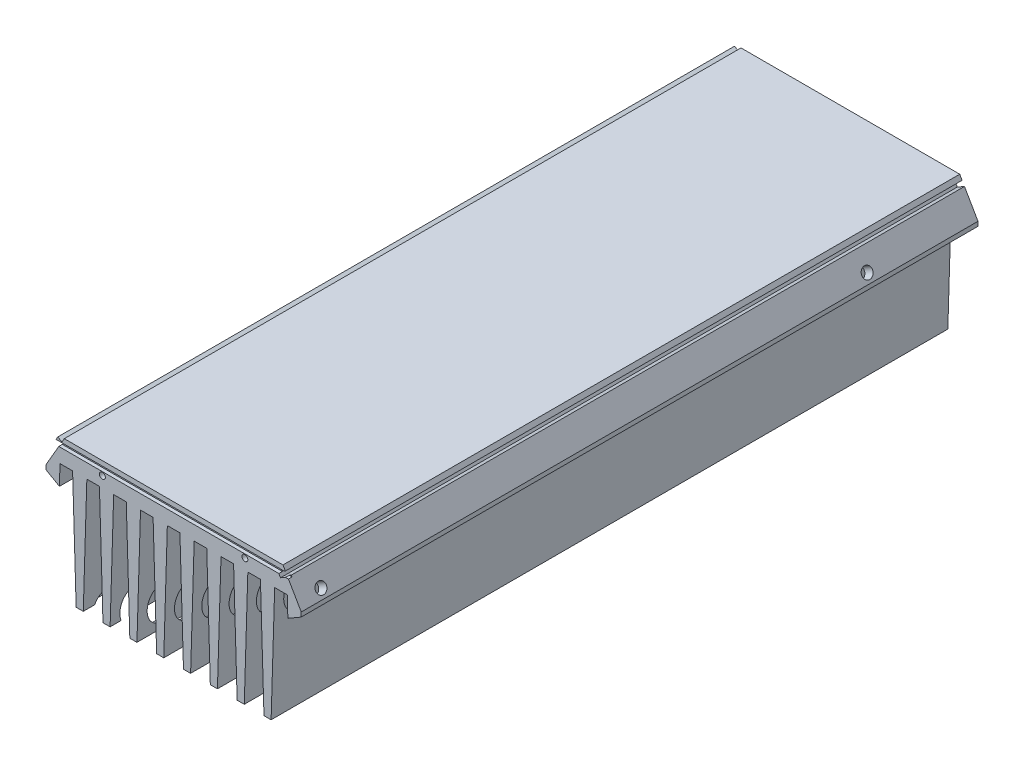
from build123d import *

# Parameters (mm, degrees)
RESSALTO_EXTRUS_O1_DEPTH   = 285
CORTE_EXTRUS_O1_DEPTH      = 1
CORTE_EXTRUS_O1_DEPTH_BACK = 286
ESBO_O3_R                  = 1.25
CORTE_EXTRUS_O2_DEPTH      = 10
ESBO_O4_W                  = 1.5
ESBO_O4_H                  = 2
CORTE_EXTRUS_O3_DEPTH      = 122.633155154
CORTE_EXTRUS_O3_DEPTH_BACK = 1
ESBO_O5_R                  = 1.65
CORTE_EXTRUS_O4_DEPTH      = 10
ESBO_O6_R                  = 2.25
CORTE_EXTRUS_O5_DEPTH      = 7.663465826
CORTE_EXTRUS_O5_DEPTH_BACK = 116.931069713
CORTE_EXTRUS_O6_START      = -4
ESBO_O8_R                  = 6
CORTE_EXTRUS_O6_DEPTH      = 100


with BuildPart() as part:
    # Esboço1 → Ressalto-extrusão1 (new body)
    with BuildSketch(Plane.XY):
        Polygon((0, 59), (155, 59), (155, 49), (153.95, 49), (152.45, 0), (149.45, 0), (147.95, 49), (142.65, 49), (141.15, 0), (138.15, 0), (136.65, 49), (131.35, 49), (129.85, 0), (126.85, 0), (125.35, 49), (120.05, 49), (118.55, 0), (115.55, 0), (114.05, 49), (108.75, 49), (107.25, 0), (104.25, 0), (102.75, 49), (97.45, 49), (95.95, 0), (92.95, 0), (91.45, 49), (86.15, 49), (84.65, 0), (81.65, 0), (80.15, 49), (74.85, 49), (73.35, 0), (70.35, 0), (68.85, 49), (63.55, 49), (62.05, 0), (59.05, 0), (57.55, 49), (52.25, 49), (50.75, 0), (47.75, 0), (46.25, 49), (40.95, 49), (39.45, 0), (36.45, 0), (34.95, 49), (29.65, 49), (28.15, 0), (25.15, 0), (23.65, 49), (18.35, 49), (16.85, 0), (13.85, 0), (12.35, 49), (7.05, 49), (5.55, 0), (2.55, 0), (1.05, 49), (0, 49), align=None)
    extrude(amount=RESSALTO_EXTRUS_O1_DEPTH)

    # Esboço2 → Corte-extrusão1 (cut, two sides)
    with BuildSketch(Plane(origin=(0, 0, 0), x_dir=(-1, 0, 0), z_dir=(0, 0, -1))) as corte_extrus_o1_sk:
        Polygon((-125.553847577, 55.535898385), (-132.053847577, 44.277568136), (-123.393593539, 39.277568136), (-123.393593539, -2.181608297), (-157.209350175, -2.181608297), (-157.209350175, 65.2147657), (-123.553847577, 65.2147657), (-123.553847577, 59), (-124.553847577, 57.267949192), (-121.522758664, 55.517949192), (-122.522758664, 53.785898385), align=None)
        Polygon((-31.446152423, 59), (7.52965499, 59), (7.52965499, -3.444074002), (-31.606406461, -3.444074002), (-31.606406461, 39.277568136), (-22.946152423, 44.277568136), (-29.446152423, 55.535898385), (-27.714101615, 56.535898385), (-28.714101615, 58.267949192), (-30.446152423, 57.267949192), align=None)
    extrude(amount=CORTE_EXTRUS_O1_DEPTH, mode=Mode.SUBTRACT)
    extrude(corte_extrus_o1_sk.sketch, amount=-CORTE_EXTRUS_O1_DEPTH_BACK, mode=Mode.SUBTRACT)

    # Esboço3 → Corte-extrusão2 (cut)
    with BuildSketch(Plane.XY.offset(285)):
        with Locations((47.5, 53.5)):
            Circle(ESBO_O3_R)
        with Locations((107.5, 53.5)):
            Circle(ESBO_O3_R)
    extrude(amount=-CORTE_EXTRUS_O2_DEPTH, mode=Mode.SUBTRACT)

    # Esboço4 → Corte-extrusão3 (cut, two sides)
    with BuildSketch(Plane(origin=(9.615, -2.555719938, 0), x_dir=(0, 0, -1), z_dir=(1, 0, 0))) as corte_extrus_o3_sk:
        with Locations((-284.25, 58.555719938)):
            Rectangle(ESBO_O4_W, ESBO_O4_H)
    extrude(amount=CORTE_EXTRUS_O3_DEPTH, mode=Mode.SUBTRACT)
    extrude(corte_extrus_o3_sk.sketch, amount=-CORTE_EXTRUS_O3_DEPTH_BACK, mode=Mode.SUBTRACT)

    # Esboço5 → Corte-extrusão4 (cut)
    with BuildSketch(Plane(origin=(-1.963135095, 1.133416575, 0), x_dir=(0, 0, 1), z_dir=(-0.866025404, 0.5, 0))):
        with Locations((45, 54.818575035)):
            Circle(ESBO_O5_R)
        with Locations((275, 54.818575035)):
            Circle(ESBO_O5_R)
    extrude(amount=-CORTE_EXTRUS_O4_DEPTH, mode=Mode.SUBTRACT)

    # Esboço6 → Corte-extrusão5 (cut, two sides)
    with BuildSketch(Plane(origin=(118.213135095, 68.250385369, 0), x_dir=(0, 0, -1), z_dir=(0.866025404, 0.5, 0))) as corte_extrus_o5_sk:
        with Locations((-275, -22.681424965)):
            Circle(ESBO_O6_R)
        with Locations((-45, -22.681424965)):
            Circle(ESBO_O6_R)
    extrude(amount=CORTE_EXTRUS_O5_DEPTH, mode=Mode.SUBTRACT)
    extrude(corte_extrus_o5_sk.sketch, amount=-CORTE_EXTRUS_O5_DEPTH_BACK, mode=Mode.SUBTRACT)

    # Esboço8 → Corte-extrusão6 (cut)
    with BuildSketch(Plane(origin=(118.213135095, 68.250385369, 0), x_dir=(0, 0, -1), z_dir=(0.866025404, 0.5, 0)).offset(CORTE_EXTRUS_O6_START)):
        with Locations((-275, -22.681424965)):
            Circle(ESBO_O8_R)
        with Locations((-45, -22.681424965)):
            Circle(ESBO_O8_R)
    extrude(amount=-CORTE_EXTRUS_O6_DEPTH, mode=Mode.SUBTRACT)


solid = part.part
